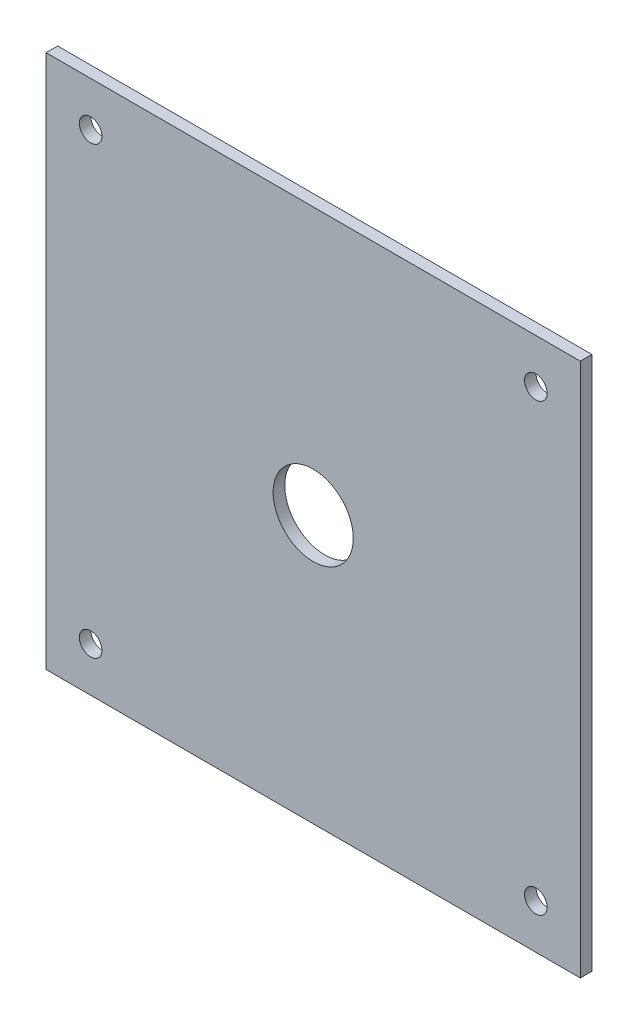
from build123d import *

# Parameters (mm, degrees)
SKETCH1_W           = 152.4
SKETCH1_H           = 152.4
SKETCH1_R           = 11.43
SKETCH1_R_2         = 3.2258
BOSS_EXTRUDE1_DEPTH = 3.302


with BuildPart() as part:
    # Sketch1 → Boss-Extrude1 (new body)
    with BuildSketch(Plane.XY):
        Rectangle(SKETCH1_W, SKETCH1_H)
        Circle(SKETCH1_R, mode=Mode.SUBTRACT)
        with Locations((-63.5, 63.5)):
            Circle(SKETCH1_R_2, mode=Mode.SUBTRACT)
        with Locations((63.5, 63.5)):
            Circle(SKETCH1_R_2, mode=Mode.SUBTRACT)
        with Locations((63.5, -63.5)):
            Circle(SKETCH1_R_2, mode=Mode.SUBTRACT)
        with Locations((-63.5, -63.5)):
            Circle(SKETCH1_R_2, mode=Mode.SUBTRACT)
    extrude(amount=BOSS_EXTRUDE1_DEPTH)


solid = part.part
